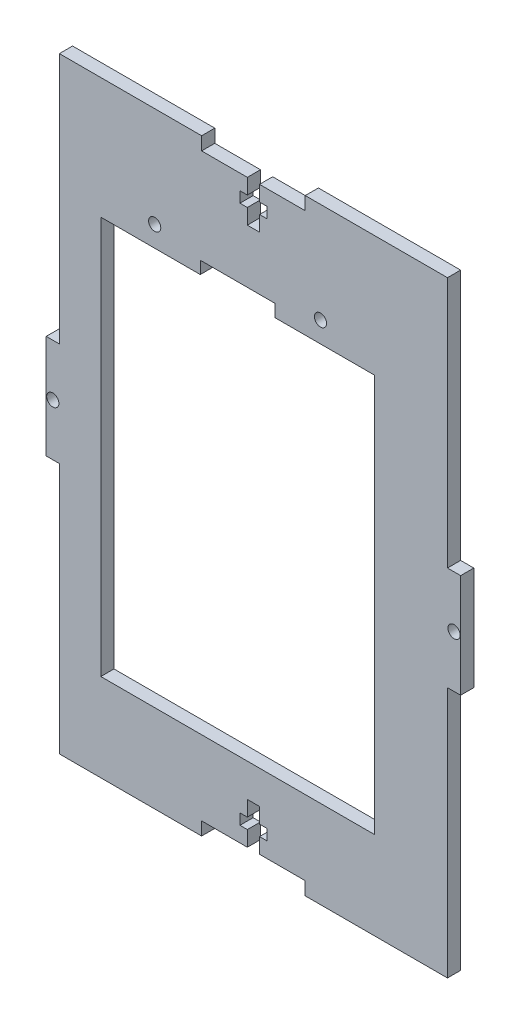
from build123d import *

# Parameters (mm, degrees)
SKETCH1_R               = 1.47
BOSS_EXTRUDE1_DEPTH     = 1.5875
SKETCH2_R               = 1.47
CUT_EXTRUDE1_DEPTH      = 4.175
CUT_EXTRUDE3_DEPTH      = 1
CUT_EXTRUDE3_DEPTH_BACK = 4.175


with BuildPart() as part:
    # Sketch1 → Boss-Extrude1 (new body, symmetric)
    with BuildSketch(Plane.XY):
        Polygon((-12.5, 73.175), (-46.825, 73.175), (-46.825, 12.5), (-50, 12.5), (-50, -12.5), (-46.825, -12.5), (-46.825, -73.175), (-12.5, -73.175), (-12.5, -70), (-1.47, -70), (-1.47, -66.3), (-3.25, -66.3), (-3.25, -63.7), (-1.47, -63.7), (-1.47, -60), (1.47, -60), (1.47, -63.7), (3.25, -63.7), (3.25, -66.3), (1.47, -66.3), (1.47, -70), (12.5, -70), (12.5, -73.175), (46.825, -73.175), (46.825, -12.5), (50, -12.5), (50, 12.5), (46.825, 12.5), (46.825, 73.175), (12.5, 73.175), (12.5, 70), (1.47, 70), (1.47, 66.3), (3.25, 66.3), (3.25, 63.7), (1.47, 63.7), (1.47, 60), (-1.47, 60), (-1.47, 63.7), (-3.25, 63.7), (-3.25, 66.3), (-1.47, 66.3), (-1.47, 70), (-12.5, 70), align=None)
        with Locations((-48.4125, 0)):
            Circle(SKETCH1_R, mode=Mode.SUBTRACT)
        with Locations((48.4125, 0)):
            Circle(SKETCH1_R, mode=Mode.SUBTRACT)
    extrude(amount=BOSS_EXTRUDE1_DEPTH, both=True)

    # Sketch2 → Cut-Extrude1 (cut, through all)
    with BuildSketch(Plane.XY.offset(1.5875)):
        with Locations((16.175, 49)):
            Circle(SKETCH2_R)
        with Locations((-23.825, 49)):
            Circle(SKETCH2_R)
    extrude(amount=-CUT_EXTRUDE1_DEPTH, mode=Mode.SUBTRACT)

    # Sketch3 → Cut-Extrude3 (cut, two sides)
    with BuildSketch(Plane.XY.offset(1.5875)) as cut_extrude3_sk:
        Polygon((-36.825, 44), (-12.825, 44), (-12.825, 47), (5.175, 47), (5.175, 44), (29.175, 44), (29.175, -52), (-36.825, -52), align=None)
    extrude(amount=CUT_EXTRUDE3_DEPTH, mode=Mode.SUBTRACT)
    extrude(cut_extrude3_sk.sketch, amount=-CUT_EXTRUDE3_DEPTH_BACK, mode=Mode.SUBTRACT)


solid = part.part
